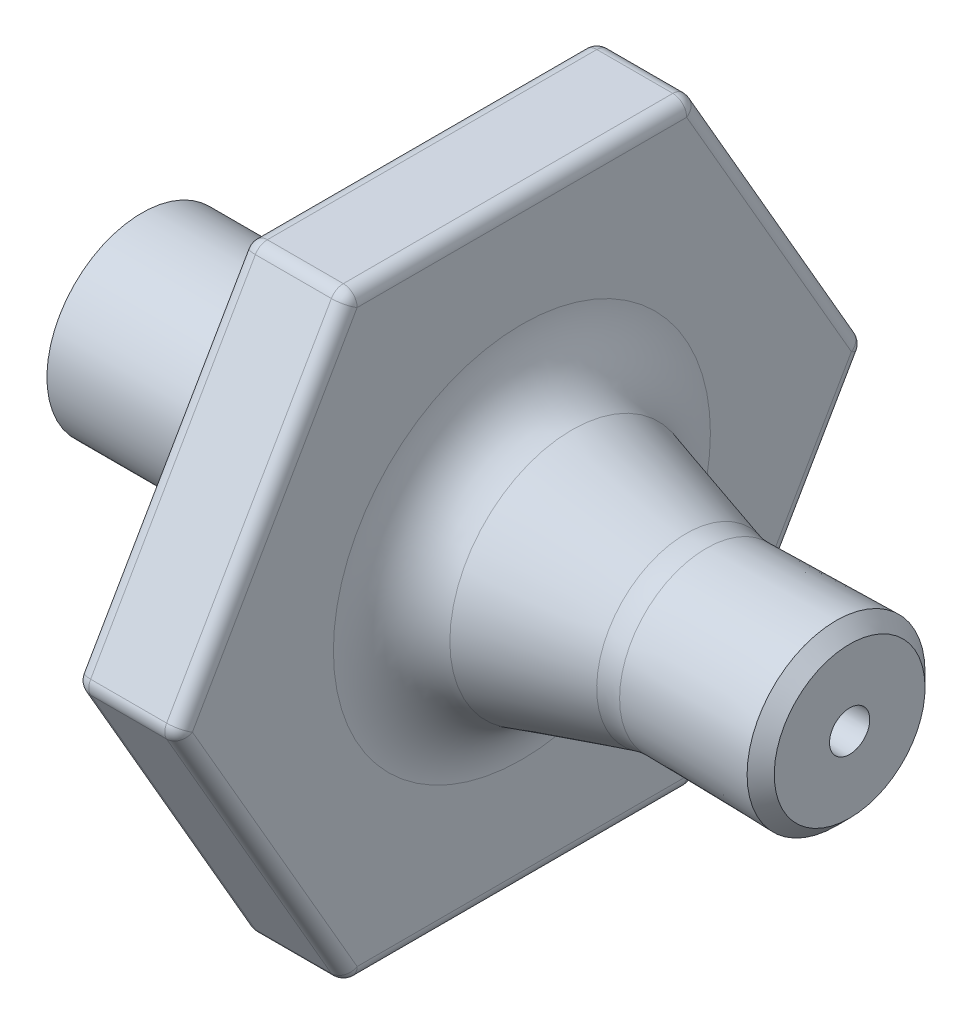
from build123d import *

# Parameters (mm, degrees)
FILLET4_R               = 3
CHAMFER1_SIZE2          = 0.393197641
CHAMFER1_SIZE           = 0.4
CUT_EXTRUDE1_DEPTH      = 10.487768718
CUT_EXTRUDE1_DEPTH_BACK = 12.0000001
FILLET5_R               = 0.4
FILLET6_R               = 2


with BuildPart() as part:
    # Sketch1 → Revolve1 (revolve)
    with BuildSketch(Plane.XY):
        Polygon((0, 1.95), (10.718918331, 1.95), (15.775669274, 0.5), (20.487768618, 0.58225), (20.487768618, 2.582554656), (16.03962094, 2.50491195), (11, 3.95), (11, 10), (8, 10), (8, 2.75), (0, 2.75), align=None)
    revolve(axis=Axis((0, 0, 0), (1, 0, 0)))

    # Fillet4
    fillet4_edges = [part.edges().sort_by_distance(p)[0] for p in [
        (15.775669274, -0.5, 0),
        (10.718918331, -1.95, 0),
    ]]
    fillet(fillet4_edges, radius=FILLET4_R)

    # Chamfer1
    chamfer1_edges = [part.edges().sort_by_distance(p)[0] for p in [
        (20.487768618, -2.582554656, 0),
    ]]
    chamfer(chamfer1_edges, length=CHAMFER1_SIZE, length2=CHAMFER1_SIZE2)

    # Sketch2 → Cut-Extrude1 (cut, two sides)
    with BuildSketch(Plane(origin=(11, 0, 0), x_dir=(0, 0, -1), z_dir=(1, 0, 0))) as cut_extrude1_sk:
        with BuildLine():
            Line((-10, 0), (-5, 8.660254038))
            ThreePointArc((-5, 8.660254038), (-8.660254038, 5), (-10, 0))
        make_face()
        with BuildLine():
            Line((-5, 8.660254038), (5, 8.660254038))
            ThreePointArc((5, 8.660254038), (0, 10), (-5, 8.660254038))
        make_face()
        with BuildLine():
            Line((5, 8.660254038), (10, 0))
            ThreePointArc((10, 0), (8.660254038, 5), (5, 8.660254038))
        make_face()
        with BuildLine():
            ThreePointArc((-10, 0), (-8.660254038, -5), (-5, -8.660254038))
            Line((-5, -8.660254038), (-10, 0))
        make_face()
        with BuildLine():
            ThreePointArc((-5, -8.660254038), (0, -10), (5, -8.660254038))
            Line((5, -8.660254038), (-5, -8.660254038))
        make_face()
        with BuildLine():
            ThreePointArc((5, -8.660254038), (8.660254038, -5), (10, 0))
            Line((10, 0), (5, -8.660254038))
        make_face()
    extrude(amount=CUT_EXTRUDE1_DEPTH, mode=Mode.SUBTRACT)
    extrude(cut_extrude1_sk.sketch, amount=-CUT_EXTRUDE1_DEPTH_BACK, mode=Mode.SUBTRACT)

    # Fillet5
    fillet5_edges = [part.edges().sort_by_distance(p)[0] for p in [
        (11, -4.330127019, -7.5),
        (8, -4.330127019, -7.5),
        (8, -8.660254038, 0),
        (8, 4.330127019, -7.5),
        (8, 4.330127019, 7.5),
        (9.5, 8.660254038, 5),
        (11, 4.330127019, 7.5),
        (9.5, 0, 10),
        (9.5, 0, -10),
        (11, 4.330127019, -7.5),
        (9.5, 8.660254038, -5),
        (9.5, -8.660254038, 5),
        (11, -8.660254038, 0),
        (9.5, -8.660254038, -5),
        (11, 8.660254038, 0),
        (8, 8.660254038, 0),
        (11, -4.330127019, 7.5),
        (8, -4.330127019, 7.5),
    ]]
    fillet(fillet5_edges, radius=FILLET5_R)

    # Fillet6
    fillet6_edges = [part.edges().sort_by_distance(p)[0] for p in [
        (11, -3.95, 0),
        (16.03962094, -2.50491195, 0),
    ]]
    fillet(fillet6_edges, radius=FILLET6_R)


solid = part.part
